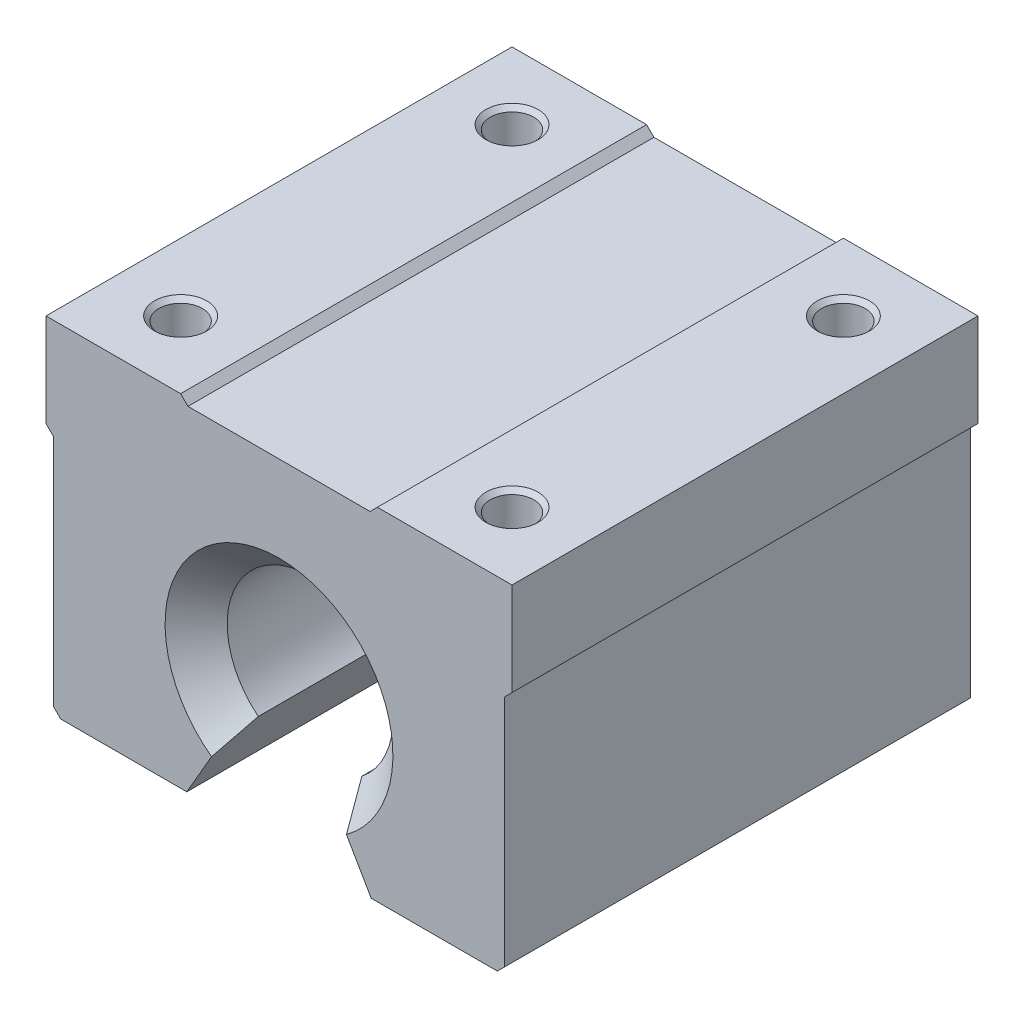
from build123d import *

# Parameters (mm, degrees)
BOSS_EXTRUDE1_DEPTH             = 22.5
M5X0_8_TAPPED_HOLE1_D           = 4.2
M5X0_8_TAPPED_HOLE1_DEPTH       = 12.0000014
M5X0_8_TAPPED_HOLE1_CSINK_D     = 5.05
M5X0_8_TAPPED_HOLE1_CSINK_ANGLE = 90
M5X0_8_TAPPED_HOLE1_TIP         = 1.2618073
CHAMFER1_SIZE                   = 3


with BuildPart() as part:
    # Sketch1 → Boss-Extrude1 (new body, symmetric)
    with BuildSketch(Plane.XY):
        with BuildLine():
            Line((-22.5, 20), (-22.5, 11))
            Line((-22.5, 11), (-21.792893219, 10.292893219))
            Line((-21.792893219, 10.292893219), (-21.792893219, -12.292893219))
            Line((-21.792893219, -12.292893219), (-21.085786438, -13))
            Line((-21.085786438, -13), (-8.900002224, -13))
            Line((-8.900002224, -13), (-5, -6.244997998))
            ThreePointArc((-5, -6.244997998), (0, 8), (5, -6.244997998))
            Line((5, -6.244997998), (8.900002224, -13))
            Line((8.900002224, -13), (21.085786438, -13))
            Line((21.085786438, -13), (21.792893219, -12.292893219))
            Line((21.792893219, -12.292893219), (21.792893219, 10.292893219))
            Line((21.792893219, 10.292893219), (22.5, 11))
            Line((22.5, 11), (22.5, 20))
            Line((22.5, 20), (9.5, 20))
            Line((9.5, 20), (8.792893219, 19.292893219))
            Line((8.792893219, 19.292893219), (-8.792893219, 19.292893219))
            Line((-8.792893219, 19.292893219), (-9.5, 20))
            Line((-9.5, 20), (-22.5, 20))
        make_face()
    extrude(amount=BOSS_EXTRUDE1_DEPTH, both=True)

    # M5x0.8 Tapped Hole1
    with Locations(Plane(origin=(16, 20, 16), x_dir=(0, 0, 1), z_dir=(0, 1, 0))):
        with Locations((0, 0), (-32, 0), (-32, -32), (0, -32)):
            CounterSinkHole(M5X0_8_TAPPED_HOLE1_D / 2, M5X0_8_TAPPED_HOLE1_CSINK_D / 2, depth=M5X0_8_TAPPED_HOLE1_DEPTH, counter_sink_angle=M5X0_8_TAPPED_HOLE1_CSINK_ANGLE)
            with Locations((0, 0, -(M5X0_8_TAPPED_HOLE1_DEPTH + M5X0_8_TAPPED_HOLE1_TIP / 2))):  # 118° drill point
                Cone(0, M5X0_8_TAPPED_HOLE1_D / 2, M5X0_8_TAPPED_HOLE1_TIP, mode=Mode.SUBTRACT)

    # Chamfer1
    chamfer1_edges = [part.edges().sort_by_distance(p)[0] for p in [
        (0, 8, -22.5),
        (0, 8, 22.5),
    ]]
    chamfer(chamfer1_edges, length=CHAMFER1_SIZE)


solid = part.part
